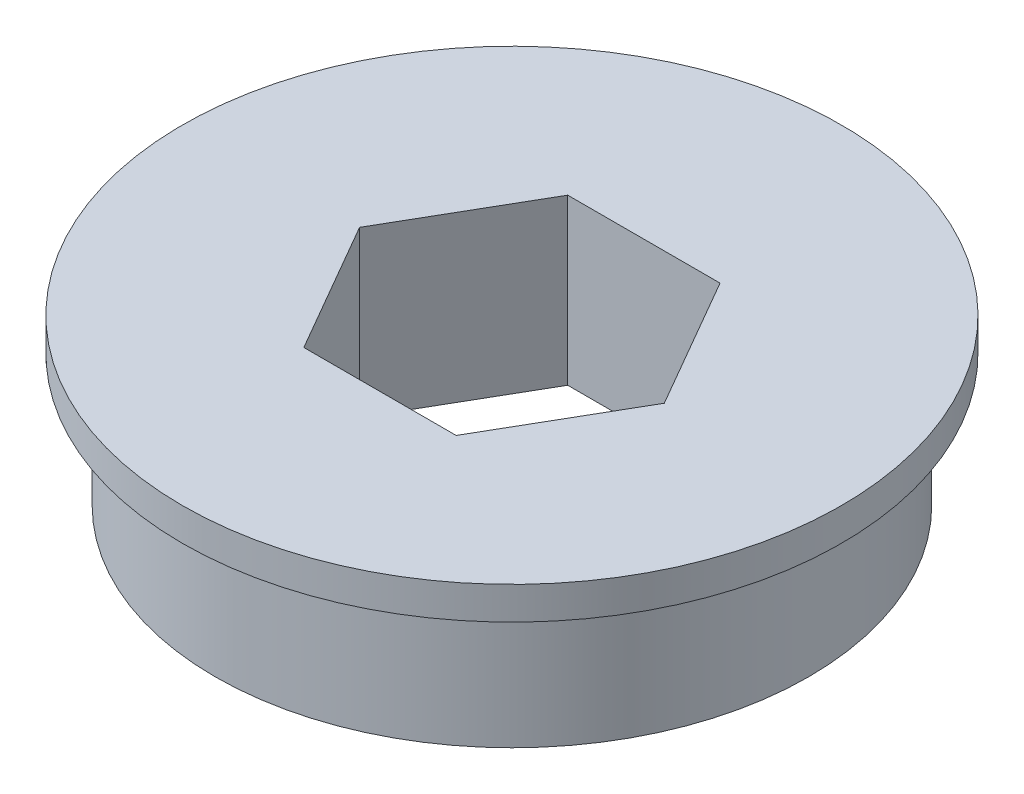
from build123d import *

# Parameters (mm, degrees)
SKETCH1_R           = 14.2875
BOSS_EXTRUDE1_DEPTH = 7.9248
SKETCH2_R           = 15.8623
SKETCH2_R_2         = 14.2875
BOSS_EXTRUDE2_DEPTH = 1.5748


with BuildPart() as part:
    # Sketch1 → Boss-Extrude1 (new body)
    with BuildSketch(Plane(origin=(0, 0, 0), x_dir=(1, 0, 0), z_dir=(0, 1, 0))):
        Circle(SKETCH1_R)
        Polygon((-3.666174209, 6.35), (-7.332348419, 0), (-3.666174209, -6.35), (3.666174209, -6.35), (7.332348419, 0), (3.666174209, 6.35), align=None, mode=Mode.SUBTRACT)
    extrude(amount=BOSS_EXTRUDE1_DEPTH)

    # Sketch2 → Boss-Extrude2 (add)
    with BuildSketch(Plane(origin=(0, 7.9248, 0), x_dir=(1, 0, 0), z_dir=(0, 1, 0))):
        Circle(SKETCH2_R)
        Circle(SKETCH2_R_2, mode=Mode.SUBTRACT)
    extrude(amount=-BOSS_EXTRUDE2_DEPTH)


solid = part.part
